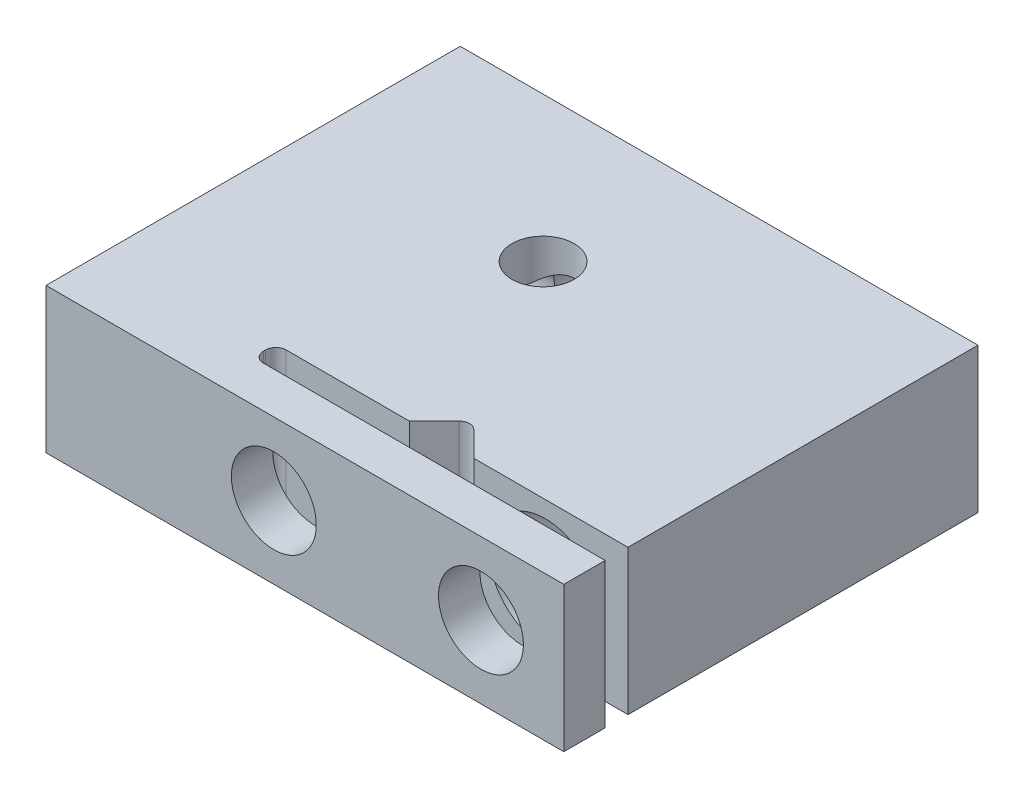
from build123d import *

# Parameters (mm, degrees)
SKETCH1_W                      = 12.5
SKETCH1_H                      = 10
BOSS_EXTRUDE1_DEPTH            = 3.5
CUT_EXTRUDE1_DEPTH             = 3.5
M2_5_CLEARANCE_HOLE1_D         = 2.7
M2_5_CLEARANCE_HOLE1_DEPTH     = 8.45
M2_5_TAPPED_HOLE1_D            = 2.05
M2_5_TAPPED_HOLE1_DEPTH        = 1
F_1_5_1_5_DIAMETER_HOLE1_D     = 1.5
F_1_5_1_5_DIAMETER_HOLE1_DEPTH = 3.5
M2_5_TAPPED_HOLE2_D            = 2.05
M2_TAPPED_HOLE3_D              = 1.6
M2_TAPPED_HOLE3_DEPTH          = 5
M2_TAPPED_HOLE3_TIP            = 0.480688495


with BuildPart() as part:
    # Sketch1 → Boss-Extrude1 (new body)
    with BuildSketch(Plane(origin=(0, 0, 0), x_dir=(1, 0, 0), z_dir=(0, 1, 0))):
        Rectangle(SKETCH1_W, SKETCH1_H)
    extrude(amount=BOSS_EXTRUDE1_DEPTH)

    # Sketch2 → Cut-Extrude1 (cut)
    with BuildSketch(Plane(origin=(0, 3.5, 0), x_dir=(1, 0, 0), z_dir=(0, 1, 0))):
        with BuildLine():
            Line((2.527817459, -3.45), (1.926776695, -2.848959236))
            ThreePointArc((1.926776695, -2.848959236), (1.75, -2.775735931), (1.573223305, -2.848959236))
            Line((1.573223305, -2.848959236), (0.972182541, -3.45))
            Line((0.972182541, -3.45), (-2, -3.45))
            ThreePointArc((-2, -3.45), (-2.176776695, -3.523223305), (-2.25, -3.7))
            Line((-2.25, -3.7), (-2.25, -3.75))
            ThreePointArc((-2.25, -3.75), (-2.176776695, -3.926776695), (-2, -4))
            Line((-2, -4), (6.25, -4))
            Line((6.25, -4), (6.25, -3.45))
            Line((6.25, -3.45), (2.527817459, -3.45))
        make_face()
    extrude(amount=-CUT_EXTRUDE1_DEPTH, mode=Mode.SUBTRACT)

    # M2.5 Clearance Hole1
    with Locations(Plane(origin=(0, 0, -5), x_dir=(-1, 0, 0), z_dir=(0, 0, -1))):
        with Locations((-4.25, 1.75)):
            Hole(M2_5_CLEARANCE_HOLE1_D / 2, depth=M2_5_CLEARANCE_HOLE1_DEPTH)

    # M2.5 Tapped Hole1
    with Locations(Plane.XY.offset(5)):
        with Locations((4.25, 1.75)):
            Hole(M2_5_TAPPED_HOLE1_D / 2, depth=M2_5_TAPPED_HOLE1_DEPTH)

    # Ø1.5 (1.5) Diameter Hole1
    with Locations(Plane(origin=(0, 3.5, 0), x_dir=(1, 0, 0), z_dir=(0, 1, 0))):
        with Locations((-0.75, 1.5)):
            Hole(F_1_5_1_5_DIAMETER_HOLE1_D / 2, depth=F_1_5_1_5_DIAMETER_HOLE1_DEPTH)

    # M2.5 Tapped Hole2 (through all)
    with Locations(Plane(origin=(0, 0, -5), x_dir=(-1, 0, 0), z_dir=(0, 0, -1))):
        with Locations((0.75, 1.75)):
            Hole(M2_5_TAPPED_HOLE2_D / 2)

    # M2 Tapped Hole3
    with Locations(Plane.ZY.offset(6.25)):
        with Locations((-2, 1.75), (2.5, 1.75)):
            Hole(M2_TAPPED_HOLE3_D / 2, depth=M2_TAPPED_HOLE3_DEPTH)
            with Locations((0, 0, -(M2_TAPPED_HOLE3_DEPTH + M2_TAPPED_HOLE3_TIP / 2))):  # 118° drill point
                Cone(0, M2_TAPPED_HOLE3_D / 2, M2_TAPPED_HOLE3_TIP, mode=Mode.SUBTRACT)


solid = part.part
